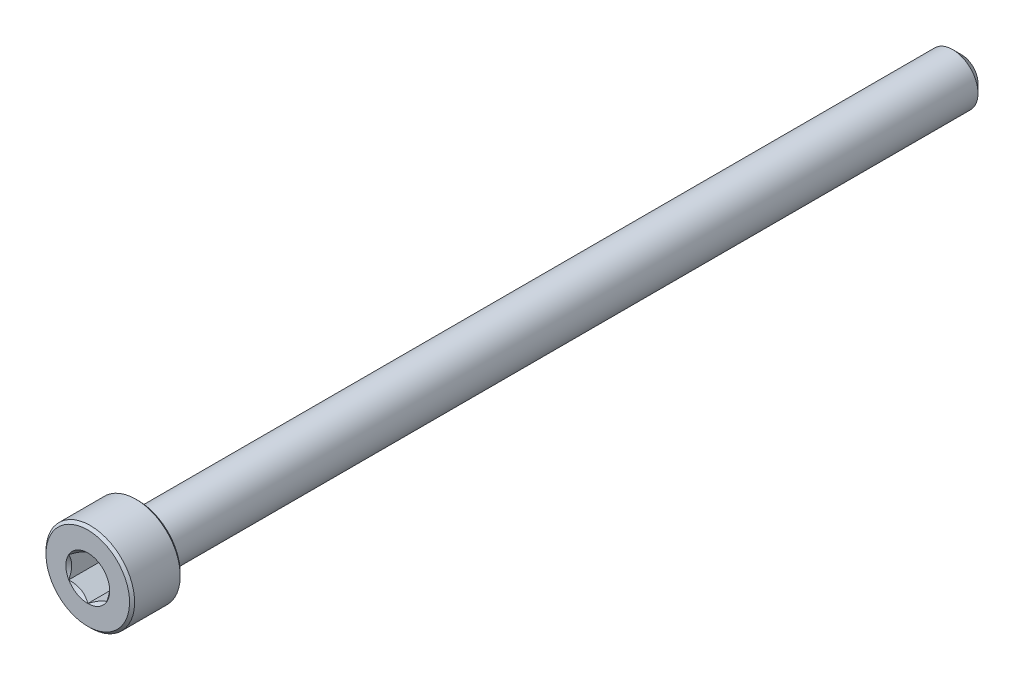
from build123d import *

# Parameters (mm, degrees)
CUT_EXTRUDE1_DEPTH = 3
SKETCH4_R          = 1.732050808
CUT_EXTRUDE2_DEPTH = 3
CUT_EXTRUDE2_DRAFT = -45


with BuildPart() as part:
    # Sketch2 → Revolve1 (revolve)
    with BuildSketch(Plane(origin=(0, 0, 0), x_dir=(0, 0, -1), z_dir=(1, 0, 0))):
        Polygon((-34.5, 0), (-34.5, 3.3), (-34.3, 3.5), (-30.7, 3.5), (-30.5, 3.3), (-30.5, 2), (33.8, 2), (34.5, 1.3), (34.5, 0), align=None)
    revolve(axis=Axis((0, 0, -34.5), (0, 0, 1)))

    # Sketch3 → Cut-Extrude1 (cut)
    with BuildSketch(Plane.XY.offset(34.5)):
        Polygon((1.5, -0.866025404), (1.5, 0.866025404), (0, 1.732050808), (-1.5, 0.866025404), (-1.5, -0.866025404), (0, -1.732050808), align=None)
    extrude(amount=-CUT_EXTRUDE1_DEPTH, mode=Mode.SUBTRACT)


with BuildPart() as cut_extrude2_tool:
    # Sketch4 → Cut-Extrude2 (with draft: the straight prism first)
    with BuildSketch(Plane.XY.offset(34.5)):
        Circle(SKETCH4_R)
    extrude(amount=-CUT_EXTRUDE2_DEPTH)
    # Cut-Extrude2: the draft: its side faces are tilted about the plane it starts from
    cut_extrude2_sides = [cut_extrude2_tool.faces().sort_by_distance(p)[0] for p in [
        (-1.732050808, 0, 33),
    ]]
    draft(cut_extrude2_sides, Plane.XY.offset(34.5), CUT_EXTRUDE2_DRAFT)


with BuildPart() as part_1:
    add(part.part)

    # Cut-Extrude2: cut by cut_extrude2_tool
    add(cut_extrude2_tool.part, mode=Mode.SUBTRACT)


solid = part_1.part
